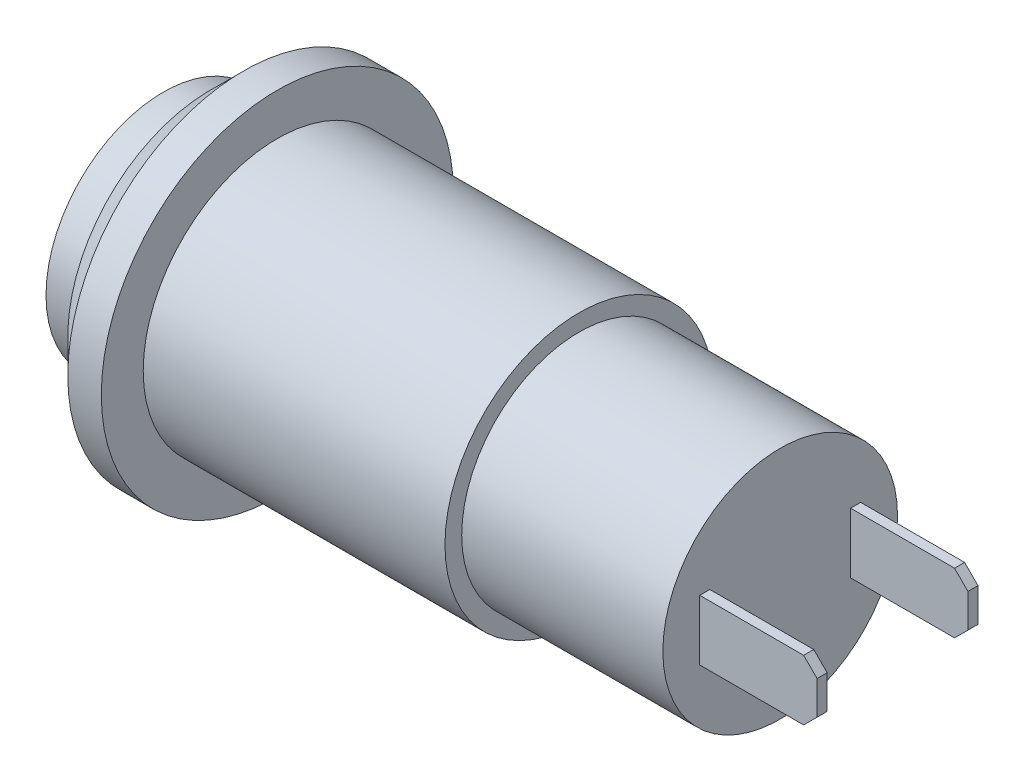
from build123d import *

# Parameters (mm, degrees)
CHAMFER_1_SIZE  = 1
SKETCH_2_W      = 0.3
SKETCH_2_H      = 1.8
EXTRUDE_1_DEPTH = 3.5
CHAMFER_3_SIZE  = 0.4


with BuildPart() as part:
    # 草图1 → 旋转1 (revolve)
    with BuildSketch(Plane.XY):
        Polygon((18.4, 0), (18.4, 3.5), (12.4, 3.5), (12.4, 4), (3.4, 4), (3.4, 5.25), (1.4, 5.25), (1.4, 3.5), (0, 3.5), (0, 0), align=None)
    revolve(axis=Axis((0, 0, 0), (1, 0, 0)))

    # 倒角1
    chamfer_1_edges = [part.edges().sort_by_distance(p)[0] for p in [
        (1.4, -5.25, 0),
    ]]
    chamfer(chamfer_1_edges, length=CHAMFER_1_SIZE)

    # 草图2 → 凸台-拉伸1 (add)
    with BuildSketch(Plane(origin=(18.4, 0, 0), x_dir=(0, 0, -1), z_dir=(1, 0, 0))):
        with Locations((2.25, 0)):
            Rectangle(SKETCH_2_W, SKETCH_2_H)
        with Locations((-2.25, 0)):
            Rectangle(SKETCH_2_W, SKETCH_2_H)
    extrude(amount=EXTRUDE_1_DEPTH)

    # 倒角3
    chamfer_3_edges = [part.edges().sort_by_distance(p)[0] for p in [
        (21.9, 0.9, -2.25),
        (21.9, -0.9, -2.25),
        (21.9, 0.9, 2.25),
        (21.9, -0.9, 2.25),
    ]]
    chamfer(chamfer_3_edges, length=CHAMFER_3_SIZE)


solid = part.part
